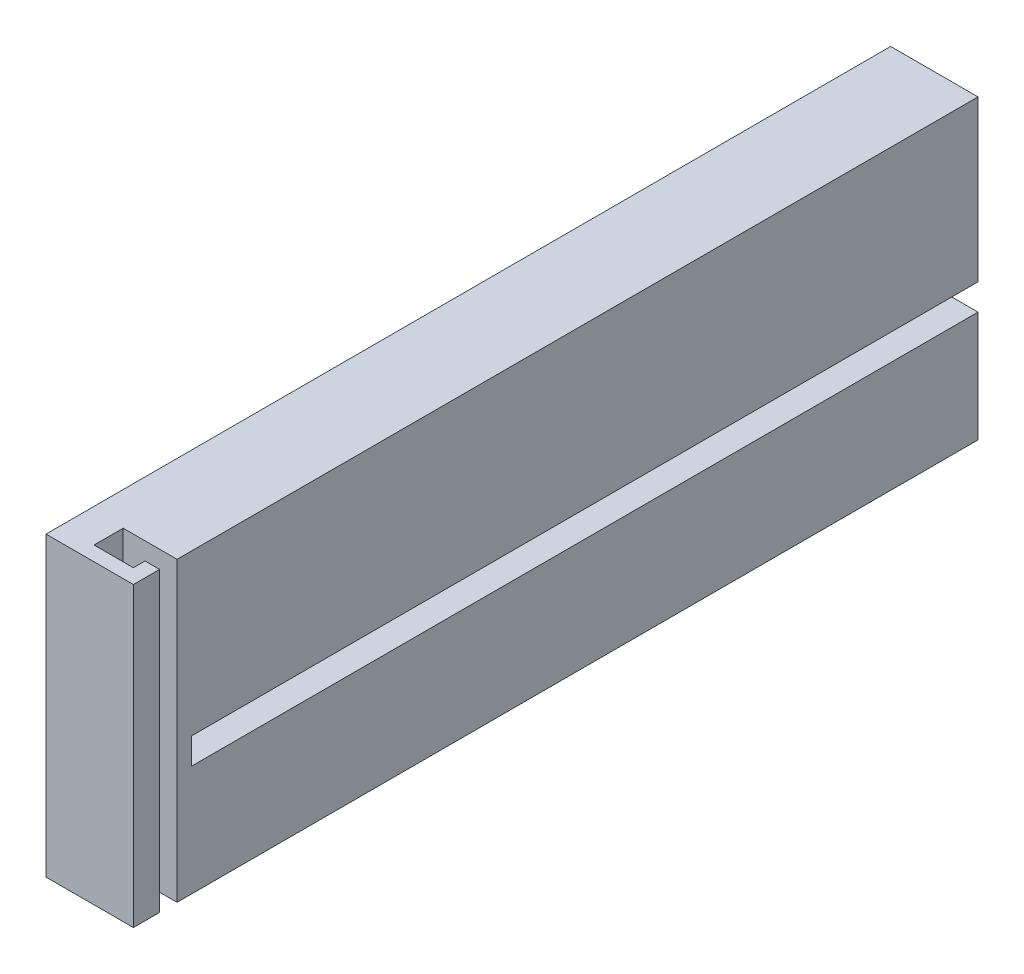
from build123d import *

# Parameters (mm, degrees)
SKETCH1_W           = 145
SKETCH1_H           = 51
BOSS_EXTRUDE1_DEPTH = 15
CUT_EXTRUDE3_DEPTH  = 52
SKETCH7_W           = 5
SKETCH7_H           = 4.5
CUT_EXTRUDE5_DEPTH  = 135


with BuildPart() as part:
    # Sketch1 → Boss-Extrude1 (new body)
    with BuildSketch(Plane(origin=(0, 0, 0), x_dir=(0, 0, -1), z_dir=(1, 0, 0))):
        with Locations((7.937921078, 5.057266603)):
            Rectangle(SKETCH1_W, SKETCH1_H)
    extrude(amount=BOSS_EXTRUDE1_DEPTH)

    # Sketch6 → Cut-Extrude3 (cut, through all)
    with BuildSketch(Plane(origin=(0, 30.557266603, 0), x_dir=(1, 0, 0), z_dir=(0, 1, 0))):
        Polygon((12.5, -60.062078922), (15, -60.062078922), (15, -57.062078922), (12.5, -57.062078922), (5.75, -57.062078922), (5.75, -62.062078922), (12.5, -62.062078922), align=None)
    extrude(amount=-CUT_EXTRUDE3_DEPTH, mode=Mode.SUBTRACT)

    # Sketch7 → Cut-Extrude5 (cut)
    with BuildSketch(Plane(origin=(0, 0, -80.437921078), x_dir=(-1, 0, 0), z_dir=(0, 0, -1))):
        with Locations((-12.5, 0.807266603)):
            Rectangle(SKETCH7_W, SKETCH7_H)
    extrude(amount=-CUT_EXTRUDE5_DEPTH, mode=Mode.SUBTRACT)


solid = part.part
